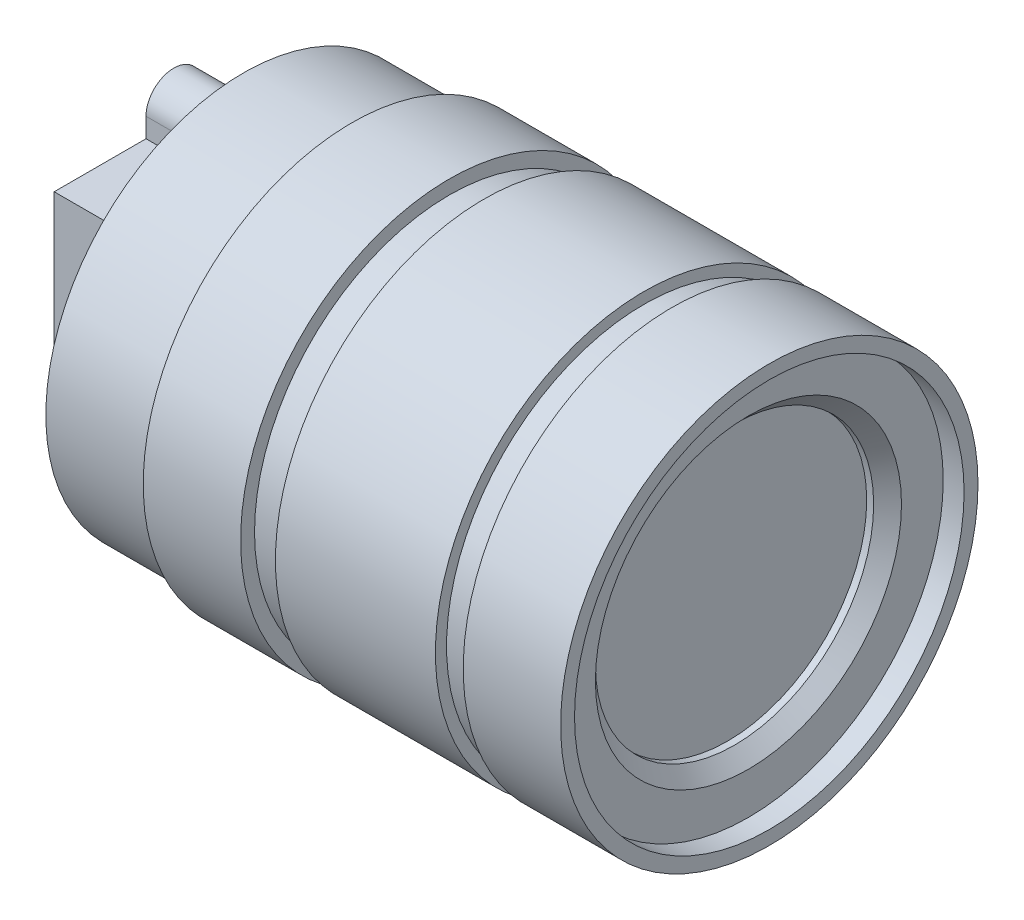
from build123d import *

# Parameters (mm, degrees)
ESQUISSE1_W             = 17.2
ESQUISSE1_H             = 17.2
BOSS_EXTRU_1_DEPTH      = 5
ESQUISSE2_R             = 1
BOSS_EXTRU_2_DEPTH      = 5
ESQUISSE3_R             = 14.2
BOSS_EXTRU_3_DEPTH      = 7.8
ESQUISSE4_R             = 15
BOSS_EXTRU_4_DEPTH      = 7
ESQUISSE5_R             = 14
BOSS_EXTRU_5_DEPTH      = 2.5
ESQUISSE6_R             = 15
BOSS_EXTRU_6_DEPTH      = 11.5
ESQUISSE7_R             = 14.2
BOSS_EXTRU_7_DEPTH      = 2
ESQUISSE8_R             = 15
BOSS_EXTRU_8_DEPTH      = 7
ESQUISSE9_R             = 14
ENL_V_MAT_EXTRU_1_DEPTH = 1.5
ESQUISSE10_R            = 10
ENL_V_MAT_EXTRU_2_DEPTH = 1.5
CHANFREIN1_SIZE         = 1


with BuildPart() as part:
    # Esquisse1 → Boss.-Extru.1 (new body)
    with BuildSketch(Plane(origin=(0, 0, 0), x_dir=(0, 0, -1), z_dir=(1, 0, 0))):
        Rectangle(ESQUISSE1_W, ESQUISSE1_H)
    extrude(amount=BOSS_EXTRU_1_DEPTH)

    # Esquisse2 → Boss.-Extru.2 (add)
    with BuildSketch(Plane(origin=(0, 0, 0), x_dir=(0, 0, -1), z_dir=(1, 0, 0))):
        with BuildLine():
            Line((-2, 8.6), (-2, 10))
            ThreePointArc((-2, 10), (0, 12), (2, 10))
            Line((2, 10), (2, 8.6))
            Line((2, 8.6), (-2, 8.6))
        make_face()
        with Locations((0, 10)):
            Circle(ESQUISSE2_R, mode=Mode.SUBTRACT)
    boss_extru_2 = extrude(amount=BOSS_EXTRU_2_DEPTH)

    # Symétrie1: Boss.-Extru.2 across plane
    add(boss_extru_2.mirror(Plane.ZX))

    # Esquisse3 → Boss.-Extru.3 (add)
    with BuildSketch(Plane(origin=(5, 0, 0), x_dir=(0, 0, -1), z_dir=(1, 0, 0))):
        Circle(ESQUISSE3_R)
    extrude(amount=BOSS_EXTRU_3_DEPTH)

    # Esquisse4 → Boss.-Extru.4 (add)
    with BuildSketch(Plane(origin=(12.8, 0, 0), x_dir=(0, 0, -1), z_dir=(1, 0, 0))):
        Circle(ESQUISSE4_R)
    extrude(amount=BOSS_EXTRU_4_DEPTH)

    # Esquisse5 → Boss.-Extru.5 (add)
    with BuildSketch(Plane(origin=(19.8, 0, 0), x_dir=(0, 0, -1), z_dir=(1, 0, 0))):
        Circle(ESQUISSE5_R)
    extrude(amount=BOSS_EXTRU_5_DEPTH)

    # Esquisse6 → Boss.-Extru.6 (add)
    with BuildSketch(Plane(origin=(22.3, 0, 0), x_dir=(0, 0, -1), z_dir=(1, 0, 0))):
        Circle(ESQUISSE6_R)
    extrude(amount=BOSS_EXTRU_6_DEPTH)

    # Esquisse7 → Boss.-Extru.7 (add)
    with BuildSketch(Plane(origin=(33.8, 0, 0), x_dir=(0, 0, -1), z_dir=(1, 0, 0))):
        Circle(ESQUISSE7_R)
    extrude(amount=BOSS_EXTRU_7_DEPTH)

    # Esquisse8 → Boss.-Extru.8 (add)
    with BuildSketch(Plane(origin=(35.8, 0, 0), x_dir=(0, 0, -1), z_dir=(1, 0, 0))):
        Circle(ESQUISSE8_R)
    extrude(amount=BOSS_EXTRU_8_DEPTH)

    # Esquisse9 → Enlèv. mat.-Extru.1 (cut)
    with BuildSketch(Plane(origin=(42.8, 0, 0), x_dir=(0, 0, -1), z_dir=(1, 0, 0))):
        Circle(ESQUISSE9_R)
    extrude(amount=-ENL_V_MAT_EXTRU_1_DEPTH, mode=Mode.SUBTRACT)

    # Esquisse10 → Enlèv. mat.-Extru.2 (cut)
    with BuildSketch(Plane(origin=(41.3, 0, 0), x_dir=(0, 0, -1), z_dir=(1, 0, 0))):
        Circle(ESQUISSE10_R)
    extrude(amount=-ENL_V_MAT_EXTRU_2_DEPTH, mode=Mode.SUBTRACT)

    # Chanfrein1
    chanfrein1_edges = [part.edges().sort_by_distance(p)[0] for p in [
        (41.3, 0, 10),
    ]]
    chamfer(chanfrein1_edges, length=CHANFREIN1_SIZE)


solid = part.part
